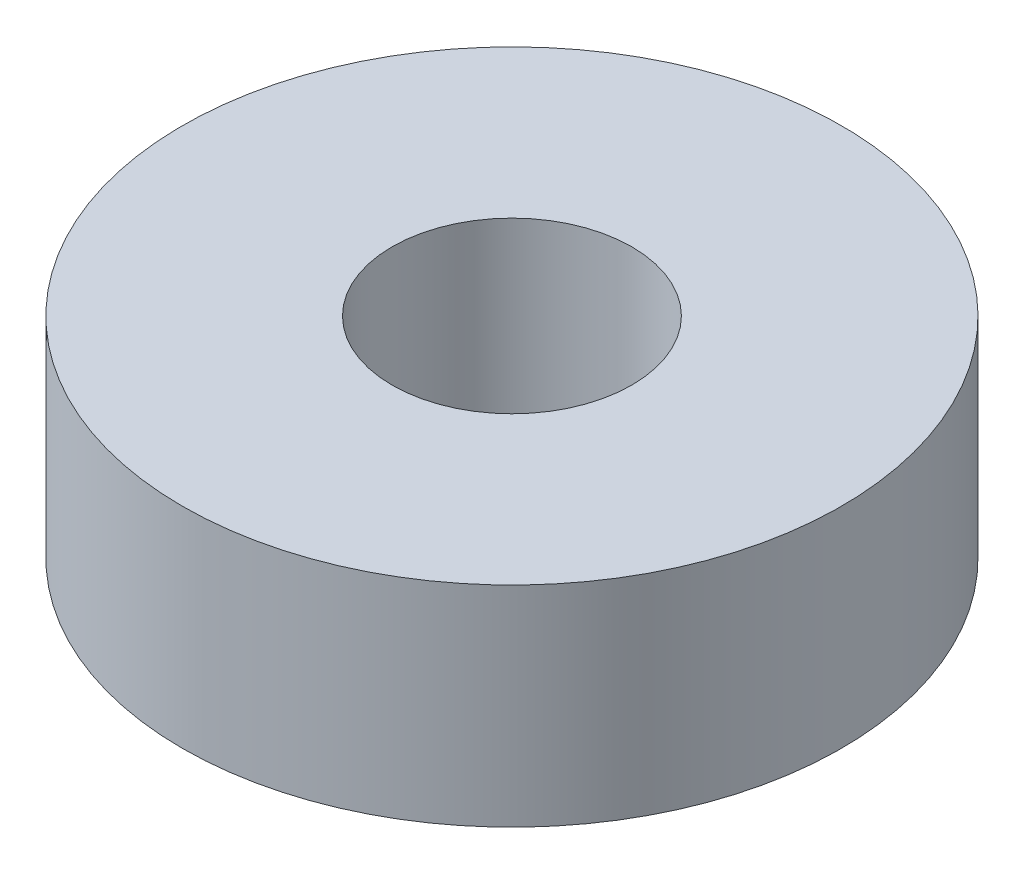
from build123d import *

# Parameters (mm, degrees)
SKETCH1_R           = 11
SKETCH1_R_2         = 4
BOSS_EXTRUDE1_DEPTH = 3.5


with BuildPart() as part:
    # Sketch1 → Boss-Extrude1 (new body, symmetric)
    with BuildSketch(Plane(origin=(0, 0, 0), x_dir=(1, 0, 0), z_dir=(0, 1, 0))):
        Circle(SKETCH1_R)
        Circle(SKETCH1_R_2, mode=Mode.SUBTRACT)
    extrude(amount=BOSS_EXTRUDE1_DEPTH, both=True)


solid = part.part
